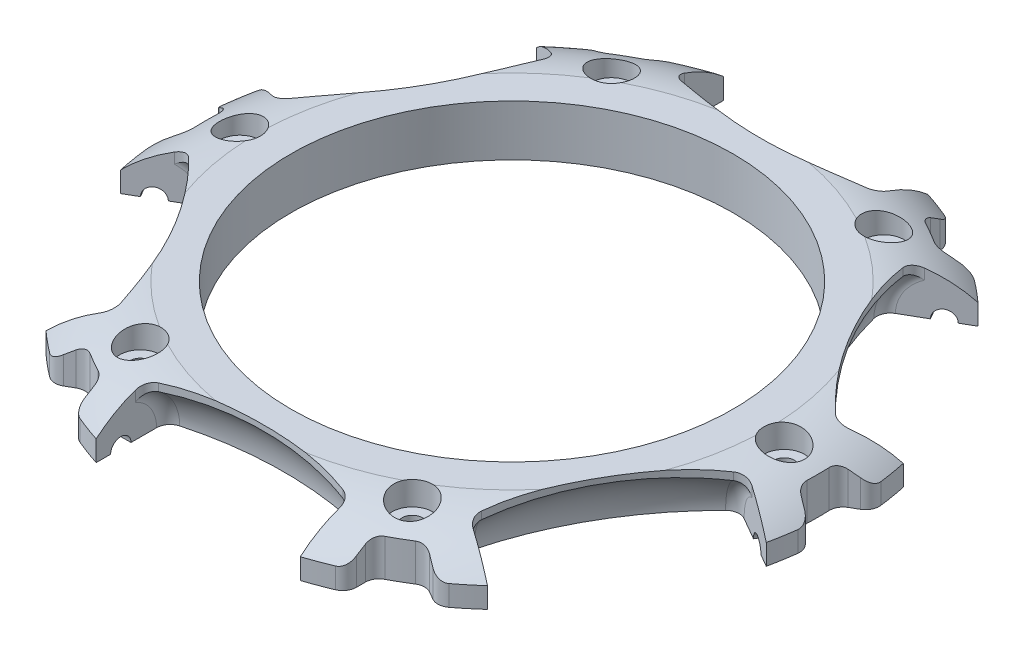
from build123d import *

# Parameters (mm, degrees)
SKETCH2_R           = 50
BOSS_EXTRUDE1_DEPTH = 7.5
CUT_EXTRUDE2_DEPTH  = 7.5
SKETCH5_R           = 1.5
CUT_EXTRUDE3_DEPTH  = 18
CIRPATTERN1_COUNT   = 6
CUT_EXTRUDE4_START  = -7.5
SKETCH6_R           = 50
CUT_EXTRUDE4_DEPTH  = 7.5
CUT_EXTRUDE5_REACH  = 9.5
SKETCH8_R           = 32.5
SKETCH9_R           = 1.5
CUT_EXTRUDE6_DEPTH  = 7.5
SKETCH10_R          = 3
CUT_EXTRUDE7_DEPTH  = 3.5
CIRPATTERN2_COUNT   = 6
FILLET1_R           = 2
FILLET2_R           = 2
FILLET3_R           = 2


with BuildPart() as part:
    # Sketch2 → Boss-Extrude1 (new body)
    with BuildSketch(Plane(origin=(0, 0, 0), x_dir=(1, 0, 0), z_dir=(0, 1, 0))):
        Circle(SKETCH2_R)
    extrude(amount=BOSS_EXTRUDE1_DEPTH)

    # Sketch3 → Cut-Revolve1 (revolve, cut)
    with BuildSketch(Plane(origin=(0, 0, 0), x_dir=(1, 0, 0), z_dir=(0, 1, 0))):
        with BuildLine():
            Line((-15, -42.5), (15, -42.5))
            Line((15, -42.5), (15, -35.732870999))
            ThreePointArc((15, -35.732870999), (0, -33.5), (-15, -35.732870999))
            Line((-15, -35.732870999), (-15, -42.5))
        make_face()
    cut_revolve1 = revolve(axis=Axis((-20.180044591, 0, 42.5), (1, 0, 0)), mode=Mode.SUBTRACT)

    # Sketch4 → Cut-Extrude2 (cut)
    with BuildSketch(Plane(origin=(0, 0, 0), x_dir=(1, 0, 0), z_dir=(0, 1, 0))):
        with BuildLine():
            Line((15, -38.877879494), (15, -47.696960071))
            ThreePointArc((15, -47.696960071), (0, -50), (-15, -47.696960071))
            Line((-15, -47.696960071), (-15, -38.877879494))
            ThreePointArc((-15, -38.877879494), (0, -36.5), (15, -38.877879494))
        make_face()
    cut_extrude2 = extrude(amount=CUT_EXTRUDE2_DEPTH, mode=Mode.SUBTRACT)

    # Sketch5 → Cut-Extrude3 (cut, symmetric)
    with BuildSketch(Plane(origin=(0, 0, 0), x_dir=(0, 0, -1), z_dir=(1, 0, 0))):
        with Locations((-42.5, 0)):
            Circle(SKETCH5_R)
    cut_extrude3 = extrude(amount=CUT_EXTRUDE3_DEPTH, both=True, mode=Mode.SUBTRACT)

    # CirPattern1: Cut-Revolve1, Cut-Extrude2, Cut-Extrude3 ×6 about axis
    cirpattern1_axis = Axis((0, 0, 0), (0, 1, 0))
    for i in range(1, CIRPATTERN1_COUNT):
        add(cut_revolve1.rotate(cirpattern1_axis, i * 360 / CIRPATTERN1_COUNT), mode=Mode.SUBTRACT)
        add(cut_extrude2.rotate(cirpattern1_axis, i * 360 / CIRPATTERN1_COUNT), mode=Mode.SUBTRACT)
        add(cut_extrude3.rotate(cirpattern1_axis, i * 360 / CIRPATTERN1_COUNT), mode=Mode.SUBTRACT)

    # Sketch6 → Cut-Extrude4 (cut)
    with BuildSketch(Plane.XZ.offset(CUT_EXTRUDE4_START)):
        Circle(SKETCH6_R)
        with BuildLine():
            Line((-28.264703056, 39.412644686), (-24.910600109, 37.476152446))
            ThreePointArc((-24.910600109, 37.476152446), (-22.5, 38.97114317), (-20, 40.311288741))
            Line((-20, 40.311288741), (-20, 44.18427322))
            ThreePointArc((-20, 44.18427322), (0, 48.5), (20, 44.18427322))
            Line((20, 44.18427322), (20, 40.311288741))
            ThreePointArc((20, 40.311288741), (22.5, 38.97114317), (24.910600109, 37.476152446))
            Line((24.910600109, 37.476152446), (28.264703056, 39.412644686))
            ThreePointArc((28.264703056, 39.412644686), (42.002232084, 24.25), (48.264703056, 4.771628534))
            Line((48.264703056, 4.771628534), (44.910600109, 2.835136295))
            ThreePointArc((44.910600109, 2.835136295), (45, 0), (44.910600109, -2.835136295))
            Line((44.910600109, -2.835136295), (48.264703056, -4.771628534))
            ThreePointArc((48.264703056, -4.771628534), (42.002232084, -24.25), (28.264703056, -39.412644686))
            Line((28.264703056, -39.412644686), (24.910600109, -37.476152446))
            ThreePointArc((24.910600109, -37.476152446), (22.5, -38.97114317), (20, -40.311288741))
            Line((20, -40.311288741), (20, -44.18427322))
            ThreePointArc((20, -44.18427322), (0, -48.5), (-20, -44.18427322))
            Line((-20, -44.18427322), (-20, -40.311288741))
            ThreePointArc((-20, -40.311288741), (-22.5, -38.97114317), (-24.910600109, -37.476152446))
            Line((-24.910600109, -37.476152446), (-28.264703056, -39.412644686))
            ThreePointArc((-28.264703056, -39.412644686), (-42.002232084, -24.25), (-48.264703056, -4.771628534))
            Line((-48.264703056, -4.771628534), (-44.910600109, -2.835136295))
            ThreePointArc((-44.910600109, -2.835136295), (-45, 0), (-44.910600109, 2.835136295))
            Line((-44.910600109, 2.835136295), (-48.264703056, 4.771628534))
            ThreePointArc((-48.264703056, 4.771628534), (-42.002232084, 24.25), (-28.264703056, 39.412644686))
        make_face(mode=Mode.SUBTRACT)
    extrude(amount=CUT_EXTRUDE4_DEPTH, mode=Mode.SUBTRACT)

    # Sketch8 → Cut-Extrude5 (cut, up to next)
    with BuildSketch(Plane.XZ, mode=Mode.PRIVATE) as cut_extrude5_sk1:
        Circle(SKETCH8_R)
    cut_extrude5_tool1 = extrude(cut_extrude5_sk1.sketch, amount=-CUT_EXTRUDE5_REACH, mode=Mode.PRIVATE) & part.part
    add(cut_extrude5_tool1.solids().sort_by_distance((0, 0, 0))[0], mode=Mode.SUBTRACT)

    # Sketch9 → Cut-Extrude6 (cut)
    with BuildSketch(Plane.XZ):
        with Locations((40, 0)):
            Circle(SKETCH9_R)
    cut_extrude6 = extrude(amount=-CUT_EXTRUDE6_DEPTH, mode=Mode.SUBTRACT)

    # Sketch10 → Cut-Extrude7 (cut)
    with BuildSketch(Plane(origin=(0, 7.5, 0), x_dir=(1, 0, 0), z_dir=(0, 1, 0))):
        with Locations((40, 0)):
            Circle(SKETCH10_R)
    cut_extrude7 = extrude(amount=-CUT_EXTRUDE7_DEPTH, mode=Mode.SUBTRACT)

    # CirPattern2: Cut-Extrude6, Cut-Extrude7 ×6 about axis
    cirpattern2_axis = Axis((0, 0, 0), (0, 1, 0))
    for i in range(1, CIRPATTERN2_COUNT):
        add(cut_extrude6.rotate(cirpattern2_axis, i * 360 / CIRPATTERN2_COUNT), mode=Mode.SUBTRACT)
        add(cut_extrude7.rotate(cirpattern2_axis, i * 360 / CIRPATTERN2_COUNT), mode=Mode.SUBTRACT)

    # Sketch7 → Cut-Revolve2 (revolve, cut)
    with BuildSketch(Plane.XY):
        with BuildLine():
            Line((-37.542025369, 7.5), (-50, 7.5))
            Line((-50, 7.5), (-50, 1.5))
            add(Edge.make_bspline(
                [(-50, 1.5), (-45.209417465, 6.974008424), (-37.542025369, 7.5)],
                knots=[0, 0, 0, 1, 1, 1], degree=2))
        make_face()
    revolve(axis=Axis((0, 0, 0), (0, 1, 0)), mode=Mode.SUBTRACT)

    # Fillet1
    fillet1_edges = [part.edges().sort_by_distance(p)[0] for p in [
        (-44.910600109, 2.740335666, -2.835136295),
        (-44.910600109, 2.740335666, 2.835136295),
        (-20, 2.740335666, -40.311288741),
        (-24.910600109, 2.740335666, -37.476152446),
        (24.910600109, 2.740335666, -37.476152446),
        (20, 2.740335666, -40.311288741),
        (44.910600109, 2.740335666, 2.835136295),
        (44.910600109, 2.740335666, -2.835136295),
        (24.910600109, 2.740335666, 37.476152446),
        (20, 2.740335666, 40.311288741),
        (-20, 2.740335666, 40.311288741),
        (-24.910600109, 2.740335666, 37.476152446),
    ]]
    fillet(fillet1_edges, radius=FILLET1_R)

    # Fillet2
    fillet2_edges = [part.edges().sort_by_distance(p)[0] for p in [
        (15, 3.262106543, 36.57102911),
        (-15, 3.262106543, 36.57102911),
        (-41.169231287, 6.258280336, 6.44855869),
        (-26.169231287, 6.258280336, 32.429320804),
        (-26.169231287, 6.258280336, -32.429320804),
        (-41.169231287, 6.258280336, -6.44855869),
        (15, 6.258280336, -38.877879494),
        (-15, 6.258280336, -38.877879494),
        (41.169231287, 6.258280336, -6.44855869),
        (26.169231287, 6.258280336, -32.429320804),
        (26.169231287, 6.258280336, 32.429320804),
        (41.169231287, 6.258280336, 6.44855869),
        (-15, 6.258280336, 38.877879494),
        (15, 6.258280336, 38.877879494),
        (39.171440251, 3.262106543, 5.295133498),
        (24.171440251, 3.262106543, 31.275895612),
        (24.171440251, 3.262106543, -31.275895612),
        (39.171440251, 3.262106543, -5.295133498),
        (-15, 3.262106543, -36.57102911),
        (15, 3.262106543, -36.57102911),
        (-39.171440251, 3.262106543, -5.295133498),
        (-24.171440251, 3.262106543, -31.275895612),
        (-24.171440251, 3.262106543, 31.275895612),
        (-39.171440251, 3.262106543, 5.295133498),
    ]]
    fillet(fillet2_edges, radius=FILLET2_R)

    # Fillet3
    fillet3_edges = [part.edges().sort_by_distance(p)[0] for p in [
        (-48.264703056, 1.514573795, 4.771628534),
        (-48.264703056, 1.514573795, -4.771628534),
        (-28.264703056, 1.514573795, -39.412644686),
        (-20, 1.514573795, -44.18427322),
        (20, 1.514573795, -44.18427322),
        (28.264703056, 1.514573795, -39.412644686),
        (48.264703056, 1.514573795, -4.771628534),
        (48.264703056, 1.514573795, 4.771628534),
        (20, 1.514573795, 44.18427322),
        (28.264703056, 1.514573795, 39.412644686),
        (-28.264703056, 1.514573795, 39.412644686),
        (-20, 1.514573795, 44.18427322),
    ]]
    fillet(fillet3_edges, radius=FILLET3_R)


solid = part.part
